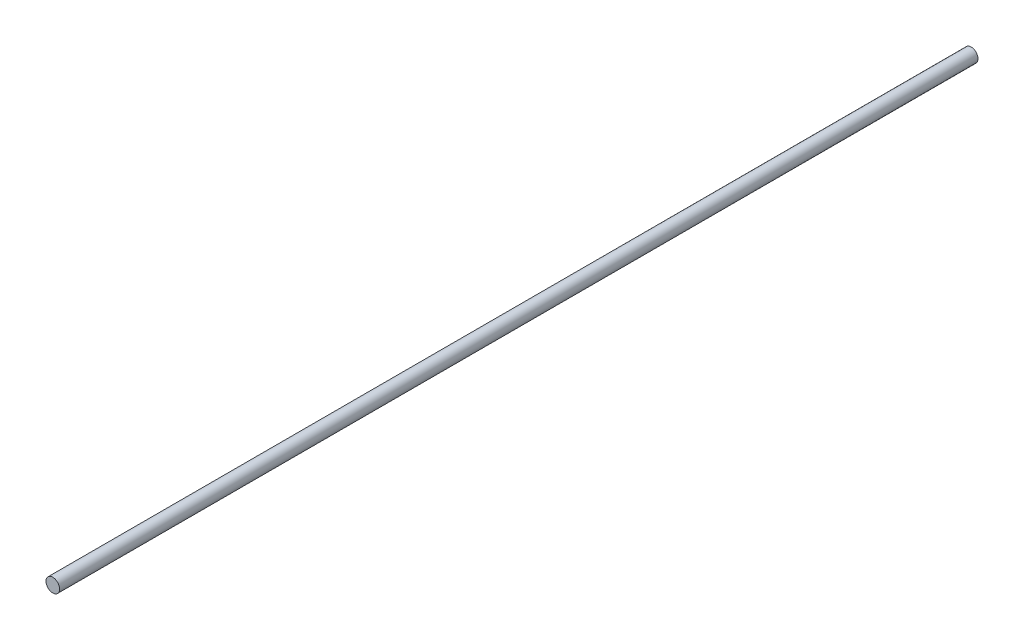
from build123d import *

# Parameters (mm, degrees)
SKETCH1_R           = 4
BOSS_EXTRUDE1_DEPTH = 540


with BuildPart() as part:
    # Sketch1 → Boss-Extrude1 (new body)
    with BuildSketch(Plane.XY):
        Circle(SKETCH1_R)
    extrude(amount=-BOSS_EXTRUDE1_DEPTH)


solid = part.part
